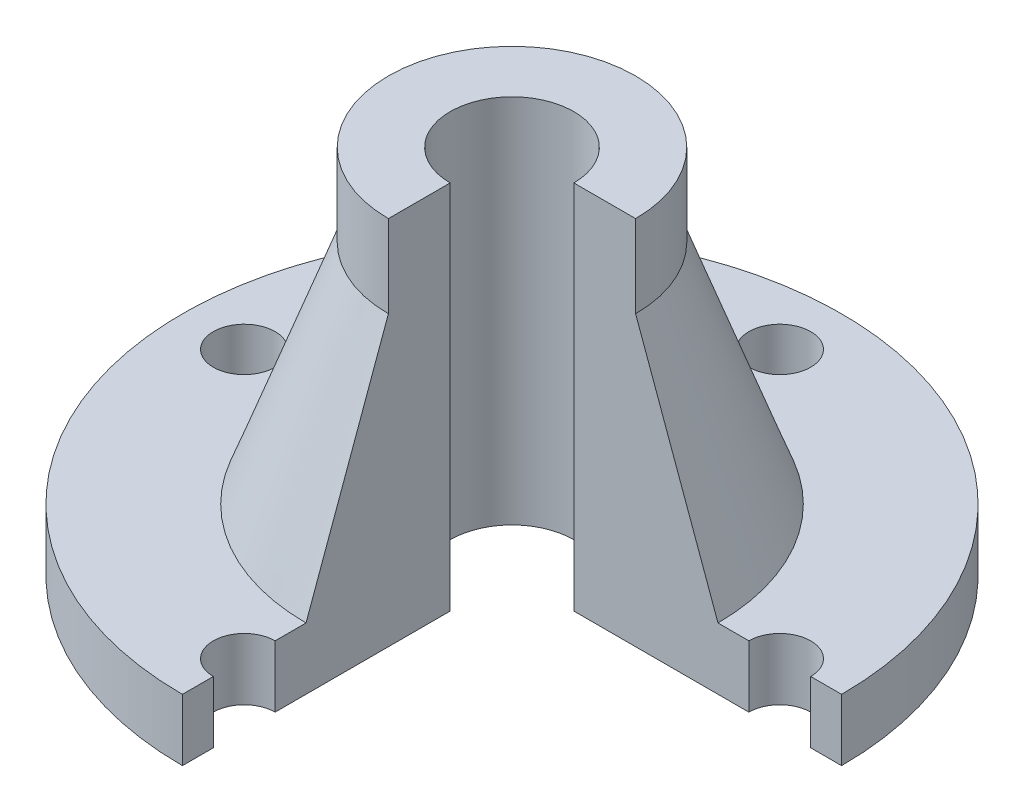
from build123d import *

# Parameters (mm, degrees)
SKETCH1_R           = 80
BOSS_EXTRUDE1_DEPTH = 15
SKETCH2_R           = 50
BOSS_EXTRUDE2_DEPTH = 75
SKETCH3_R           = 15
CUT_EXTRUDE1_DEPTH  = 91
SKETCH5_R           = 7.5
CUT_EXTRUDE2_DEPTH  = 75
CIRPATTERN1_COUNT   = 4
CUT_EXTRUDE3_DEPTH  = 91


with BuildPart() as part:
    # Sketch1 → Boss-Extrude1 (new body)
    with BuildSketch(Plane(origin=(0, 0, 0), x_dir=(1, 0, 0), z_dir=(0, 1, 0))):
        Circle(SKETCH1_R)
    extrude(amount=BOSS_EXTRUDE1_DEPTH)

    # Sketch2 → Boss-Extrude2 (add)
    with BuildSketch(Plane(origin=(0, 15, 0), x_dir=(1, 0, 0), z_dir=(0, 1, 0))):
        Circle(SKETCH2_R)
    extrude(amount=BOSS_EXTRUDE2_DEPTH)

    # Sketch3 → Cut-Extrude1 (cut, through all)
    with BuildSketch(Plane(origin=(0, 0, 0), x_dir=(1, 0, 0), z_dir=(0, 1, 0))):
        Circle(SKETCH3_R)
    extrude(amount=CUT_EXTRUDE1_DEPTH, mode=Mode.SUBTRACT)

    # Sketch4 → Cut-Revolve1 (revolve, cut)
    with BuildSketch(Plane(origin=(0, 0, 0), x_dir=(0, 0, -1), z_dir=(1, 0, 0))):
        Polygon((-30, 90), (-30, 70), (-50, 15), (-50, 90), align=None)
    revolve(axis=Axis((0, 90, 0), (0, -1, 0)), mode=Mode.SUBTRACT)

    # Sketch5 → Cut-Extrude2 (cut)
    with BuildSketch(Plane.XZ):
        with Locations((0, -65)):
            Circle(SKETCH5_R)
    cut_extrude2 = extrude(amount=-CUT_EXTRUDE2_DEPTH, mode=Mode.SUBTRACT)

    # CirPattern1: Cut-Extrude2 ×4 about axis
    cirpattern1_axis = Axis((0, 0, 0), (0, 1, 0))
    for i in range(1, CIRPATTERN1_COUNT):
        add(cut_extrude2.rotate(cirpattern1_axis, i * 360 / CIRPATTERN1_COUNT), mode=Mode.SUBTRACT)

    # Sketch6 → Cut-Extrude3 (cut, through all)
    with BuildSketch(Plane.XZ):
        Polygon((0, 80), (0, 0), (80, 0), (80, 86.210661468), align=None)
    extrude(amount=-CUT_EXTRUDE3_DEPTH, mode=Mode.SUBTRACT)


solid = part.part
